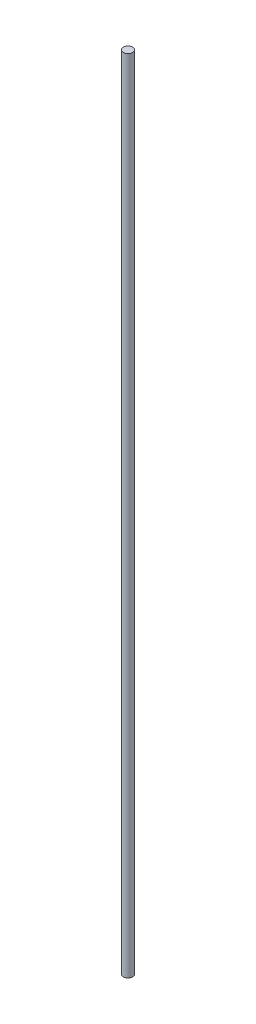
from build123d import *

# Parameters (mm, degrees)
CROQUIS2_R              = 0.875
SALIENTE_EXTRUIR1_DEPTH = 150


with BuildPart() as part:
    # Croquis2 → Saliente-Extruir1 (new body)
    with BuildSketch(Plane(origin=(0, 0, 0), x_dir=(1, 0, 0), z_dir=(0, 1, 0))):
        Circle(CROQUIS2_R)
    extrude(amount=SALIENTE_EXTRUIR1_DEPTH)


solid = part.part
